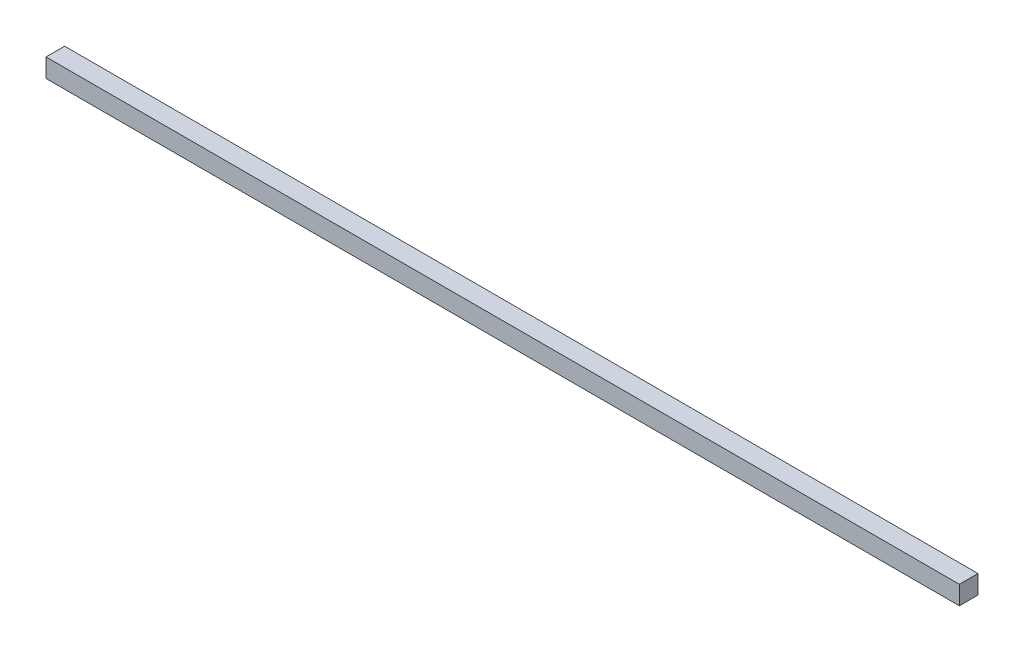
from build123d import *

# Parameters (mm, degrees)
SKETCH_1_W      = 1200
SKETCH_1_H      = 24.5
EXTRUDE_1_DEPTH = 24.5


with BuildPart() as part:
    # 草图1 → 凸台-拉伸1 (new body)
    with BuildSketch(Plane(origin=(0, 0, 0), x_dir=(1, 0, 0), z_dir=(0, 1, 0))):
        Rectangle(SKETCH_1_W, SKETCH_1_H)
    extrude(amount=EXTRUDE_1_DEPTH)


solid = part.part
